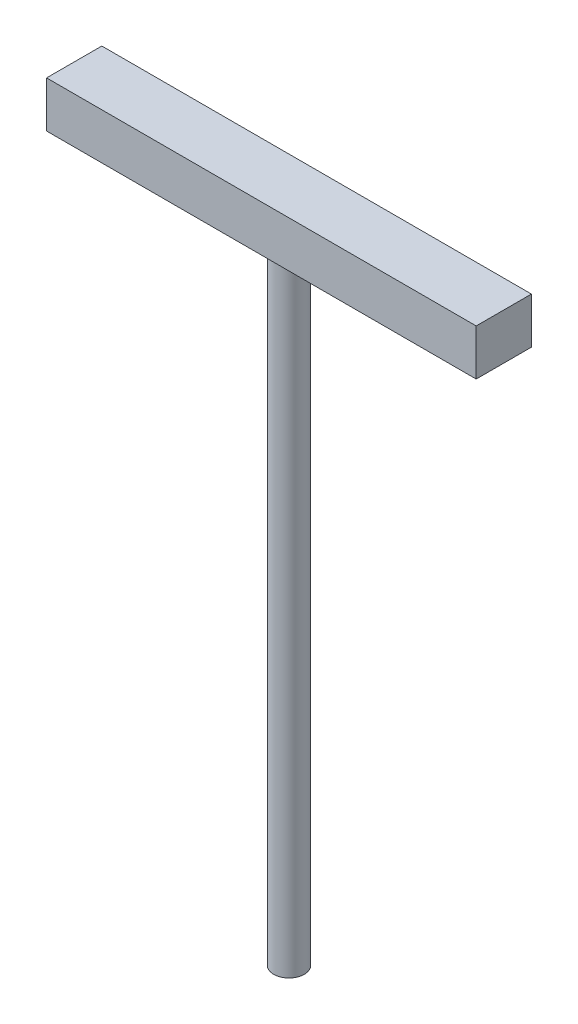
from build123d import *

# Parameters (mm, degrees)
SKETCH1_W           = 11.43
SKETCH1_H           = 9.525
BOSS_EXTRUDE1_DEPTH = 88.9
SKETCH2_R           = 3.175
BOSS_EXTRUDE2_DEPTH = 130.175


with BuildPart() as part:
    # Sketch1 → Boss-Extrude1 (new body)
    with BuildSketch(Plane(origin=(0, 0, 0), x_dir=(0, 0, -1), z_dir=(1, 0, 0))):
        Rectangle(SKETCH1_W, SKETCH1_H)
    extrude(amount=BOSS_EXTRUDE1_DEPTH)

    # Sketch2 → Boss-Extrude2 (add)
    with BuildSketch(Plane.XZ.offset(4.7625)):
        with Locations((44.45, 0)):
            Circle(SKETCH2_R)
    extrude(amount=BOSS_EXTRUDE2_DEPTH)


solid = part.part
